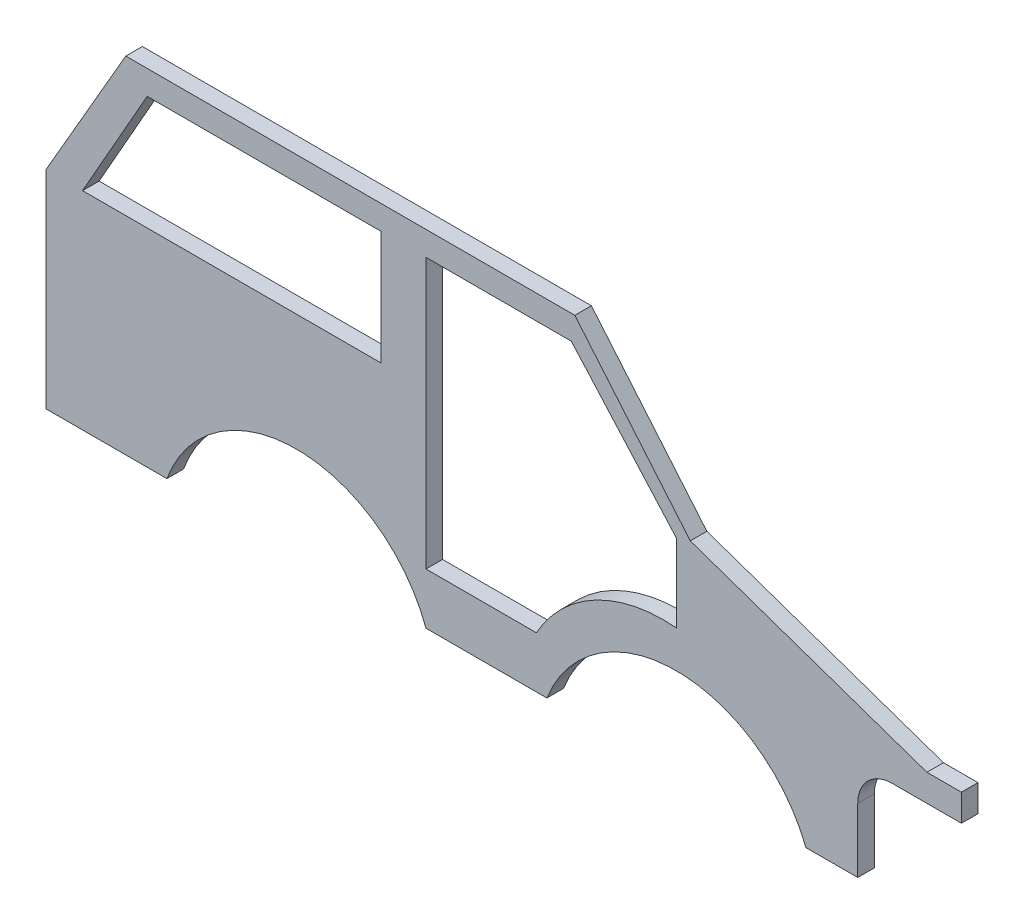
from build123d import *

# Parameters (mm, degrees)
SALIENTE_EXTRUIR2_DEPTH = 4.8


with BuildPart() as part:
    # Croquis1 → Saliente-Extruir2 (new body)
    with BuildSketch(Plane.XY):
        with BuildLine():
            Line((-17.5, 0), (17.5, 0))
            ThreePointArc((17.5, 0), (55, 25.580282757), (92.5, 0))
            Line((92.5, 0), (107.5, 0))
            Line((107.5, 0), (107.5, 18.6))
            ThreePointArc((107.5, 18.6), (110.428932188, 25.671067812), (117.5, 28.6))
            Line((117.5, 28.6), (137.513068614, 28.6))
            Line((137.513068614, 28.6), (137.513068614, 36.4))
            Line((137.513068614, 36.4), (127.513068614, 36.4))
            Line((127.513068614, 36.4), (59.018966471, 60.165688958))
            Line((59.018966471, 60.165688958), (25.594010768, 100))
            Line((25.594010768, 100), (-104.405989232, 100))
            Line((-104.405989232, 100), (-127.5, 60))
            Line((-127.5, 60), (-127.5, 0))
            Line((-127.5, 0), (-92.5, 0))
            ThreePointArc((-92.5, 0), (-55, 26.176046527), (-17.5, 0))
        make_face()
        Polygon((-116.916975087, 60), (-98.205737613, 92.999006125), (-30.488878185, 92.999006125), (-30.488878185, 60), align=None, mode=Mode.SUBTRACT)
        with BuildLine():
            Line((-17.5, 92.999006125), (-17.5, 14.847400468))
            Line((-17.5, 14.847400468), (14.466697892, 14.847400468))
            ThreePointArc((14.466697892, 14.847400468), (31.548577024, 31.595792779), (55, 36.321255728))
            Line((55, 36.321255728), (55, 58.860748488))
            Line((55, 58.860748488), (24.578803898, 92.999006125))
            Line((24.578803898, 92.999006125), (-17.5, 92.999006125))
        make_face(mode=Mode.SUBTRACT)
    extrude(amount=SALIENTE_EXTRUIR2_DEPTH)


solid = part.part
